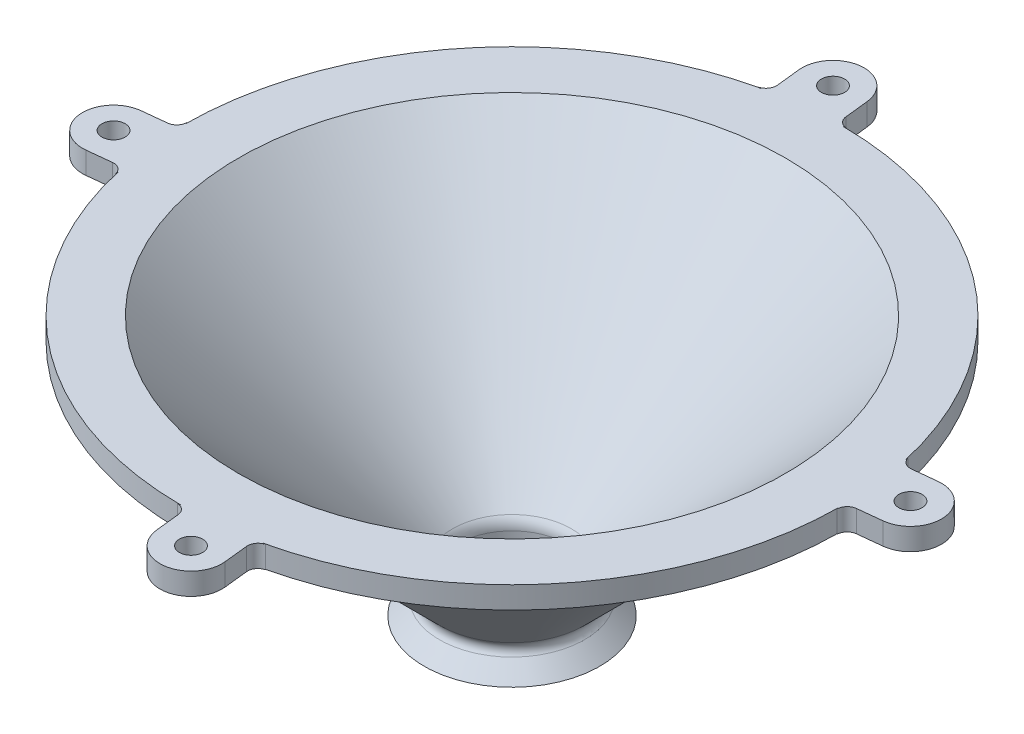
from build123d import *

# Parameters (mm, degrees)
FILLET1_R           = 2
FILLET2_R           = 6
SCALE1_SCALE        = 0.85
SKETCH4_R           = 10.6
CUT_EXTRUDE2_DEPTH  = 51.23590774
SKETCH9_R           = 2.25
BOSS_EXTRUDE1_DEPTH = 4.25
FILLET4_R           = 3


with BuildPart() as part:
    # Sketch2 → Revolve1 (revolve)
    with BuildSketch(Plane(origin=(0, 0, 0), x_dir=(0, 0, -1), z_dir=(1, 0, 0))):
        Polygon((10.1, 0), (10.1, 6.971067812), (62.23, 59.101067812), (75, 59.101067812), (75, 54.101067812), (64.301067812, 54.101067812), (15.1, 4.9), (20, 0), align=None)
    revolve(axis=Axis((0, 0, 0), (0, 1, 0)))

    # Fillet1
    fillet1_edges = [part.edges().sort_by_distance(p)[0] for p in [
        (0, 4.9, 15.1),
    ]]
    fillet(fillet1_edges, radius=FILLET1_R)

    # Fillet2
    fillet2_edges = [part.edges().sort_by_distance(p)[0] for p in [
        (0, 6.971067812, 10.1),
    ]]
    fillet(fillet2_edges, radius=FILLET2_R)


with BuildPart() as part_1:
    # Scale1: scaled about (0, 40.216103787, 0)
    add(part.part.scale(SCALE1_SCALE).moved(Location((0, 6.032415568, 0))))

    # Sketch4 → Cut-Extrude2 (cut, through all)
    with BuildSketch(Plane.XZ.offset(-6.032415568)):
        Circle(SKETCH4_R)
    extrude(amount=-CUT_EXTRUDE2_DEPTH, mode=Mode.SUBTRACT)

    # Sketch9 → Boss-Extrude1 (add)
    with BuildSketch(Plane.XZ.offset(-52.018323208)):
        with BuildLine():
            Line((-62.154465971, 14.492663996), (-63.814937276, -0.932057036))
            ThreePointArc((-63.814937276, -0.932057036), (-64.336549414, 0.385954164), (-65.60066074, 1.027246064))
            Line((-65.60066074, 1.027246064), (-70.240082919, 1.526679887))
            ThreePointArc((-70.240082919, 1.526679887), (-75.563426885, 8.134403325), (-68.955703447, 13.45774729))
            Line((-68.955703447, 13.45774729), (-64.316281268, 12.958313466))
            ThreePointArc((-64.316281268, 12.958313466), (-62.944644221, 13.315867039), (-62.154465971, 14.492663996))
        make_face()
        with Locations((-69.597893183, 7.492213588)):
            Circle(SKETCH9_R, mode=Mode.SUBTRACT)
        with BuildLine():
            Line((-0.932057036, 63.814937276), (14.492663996, 62.154465971))
            ThreePointArc((14.492663996, 62.154465971), (13.315867039, 62.944644221), (12.958313466, 64.316281268))
            Line((12.958313466, 64.316281268), (13.45774729, 68.955703447))
            ThreePointArc((13.45774729, 68.955703447), (8.134403325, 75.563426885), (1.526679887, 70.240082919))
            Line((1.526679887, 70.240082919), (1.027246064, 65.60066074))
            ThreePointArc((1.027246064, 65.60066074), (0.385954164, 64.336549414), (-0.932057036, 63.814937276))
        make_face()
        with Locations((7.492213588, 69.597893183)):
            Circle(SKETCH9_R, mode=Mode.SUBTRACT)
        with BuildLine():
            Line((63.814937276, 0.932057036), (62.154465971, -14.492663996))
            ThreePointArc((62.154465971, -14.492663996), (62.944644221, -13.315867039), (64.316281268, -12.958313466))
            Line((64.316281268, -12.958313466), (68.955703447, -13.45774729))
            ThreePointArc((68.955703447, -13.45774729), (75.563426885, -8.134403325), (70.240082919, -1.526679887))
            Line((70.240082919, -1.526679887), (65.60066074, -1.027246064))
            ThreePointArc((65.60066074, -1.027246064), (64.336549414, -0.385954164), (63.814937276, 0.932057036))
        make_face()
        with Locations((69.597893183, -7.492213588)):
            Circle(SKETCH9_R, mode=Mode.SUBTRACT)
        with BuildLine():
            Line((-14.492663996, -62.154465971), (0.932057036, -63.814937276))
            ThreePointArc((0.932057036, -63.814937276), (-0.385954164, -64.336549414), (-1.027246064, -65.60066074))
            Line((-1.027246064, -65.60066074), (-1.526679887, -70.240082919))
            ThreePointArc((-1.526679887, -70.240082919), (-8.134403325, -75.563426885), (-13.45774729, -68.955703447))
            Line((-13.45774729, -68.955703447), (-12.958313466, -64.316281268))
            ThreePointArc((-12.958313466, -64.316281268), (-13.315867039, -62.944644221), (-14.492663996, -62.154465971))
        make_face()
        with Locations((-7.492213588, -69.597893183)):
            Circle(SKETCH9_R, mode=Mode.SUBTRACT)
    extrude(amount=-BOSS_EXTRUDE1_DEPTH)

    # Fillet4
    fillet4_edges = [part_1.edges().sort_by_distance(p)[0] for p in [
        (-7.495331881, 13.972823208, 7.495331881),
        (0, 52.018323208, 54.65590764),
    ]]
    fillet(fillet4_edges, radius=FILLET4_R)


solid = part_1.part
